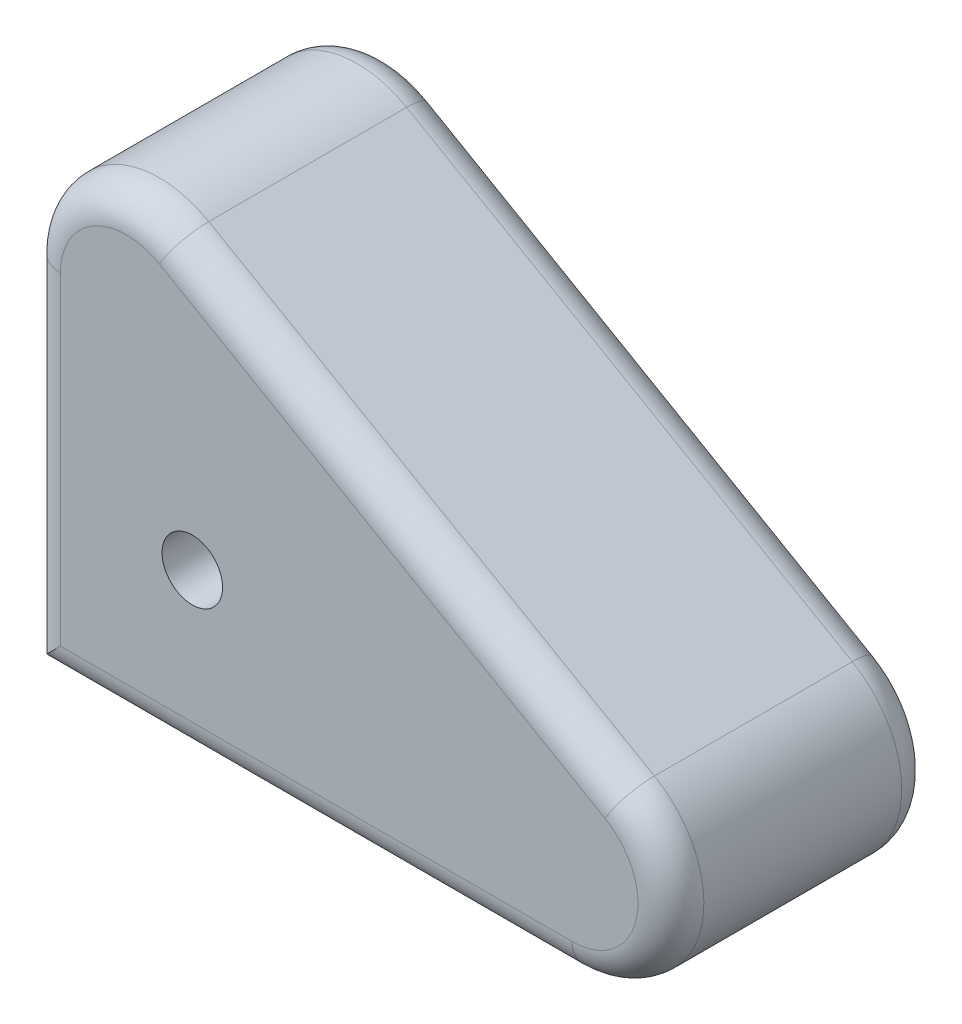
from build123d import *

# Parameters (mm, degrees)
SKETCH1_R           = 5.830122714
BOSS_EXTRUDE1_DEPTH = 50.8
FILLET1_R           = 6.35


with BuildPart() as part:
    # Sketch1 → Boss-Extrude1 (new body)
    with BuildSketch(Plane.XY):
        with BuildLine():
            Line((-31.75, -31.75), (73.130794165, -31.75))
            ThreePointArc((73.130794165, -31.75), (91.531681156, -17.630502809), (82.655794165, 3.797783942))
            Line((82.655794165, 3.797783942), (-3.175, 53.352216058))
            ThreePointArc((-3.175, 53.352216058), (-22.225, 53.352216058), (-31.75, 36.854432116))
            Line((-31.75, 36.854432116), (-31.75, -31.75))
        make_face()
        Circle(SKETCH1_R, mode=Mode.SUBTRACT)
    extrude(amount=BOSS_EXTRUDE1_DEPTH)

    # Fillet1
    fillet1_edges = [part.edges().sort_by_distance(p)[0] for p in [
        (91.531681156, -17.630502809, 50.8),
        (39.740397082, 28.575, 50.8),
        (-22.225, 53.352216058, 50.8),
        (-31.75, 2.552216058, 50.8),
        (-22.225, 53.352216058, 0),
        (39.740397082, 28.575, 0),
        (91.531681156, -17.630502809, 0),
        (20.690397082, -31.75, 0),
        (-31.75, 2.552216058, 0),
        (20.690397082, -31.75, 50.8),
    ]]
    fillet(fillet1_edges, radius=FILLET1_R)


solid = part.part
